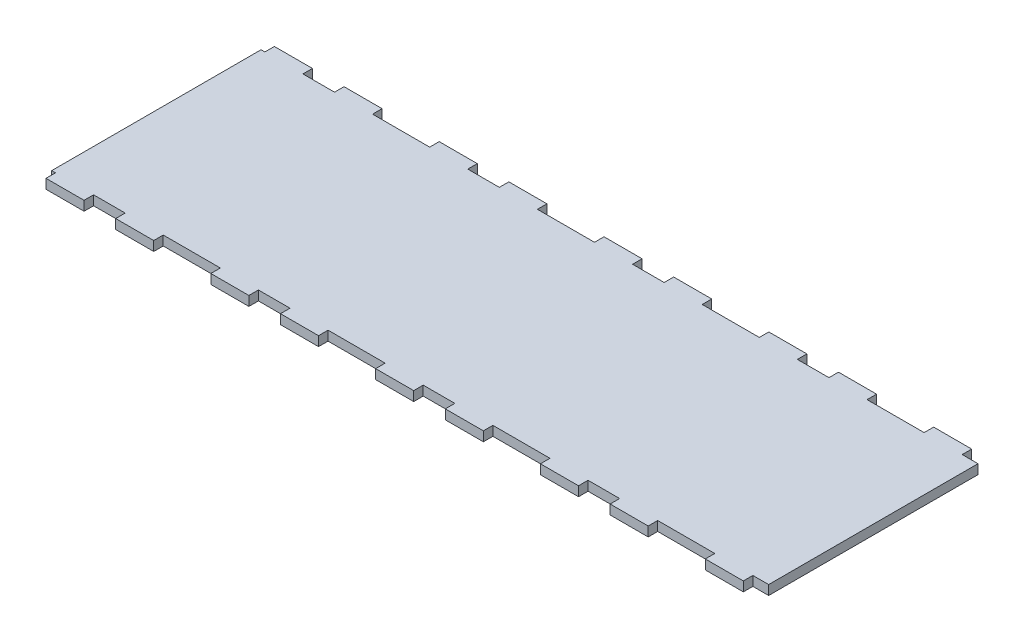
from build123d import *

# Parameters (mm, degrees)
SKETCH1_W                 = 516.930563546
SKETCH1_H                 = 152.4
BOSS_EXTRUDE1_DEPTH       = 6.35
SKETCH2_W                 = 21.085226308
SKETCH2_H                 = 6.35
SKETCH2_W_2               = 19.05
CUT_EXTRUDE1_DEPTH        = 7.35
LPATTERN1_COUNT           = 3
LPATTERN1_PITCH           = 109.985226308
LPATTERN1_COL_COUNT       = 3
LPATTERN1_COL_PITCH       = 109.985226308
MIRROR1_COPY_1_SKETCH_W   = 21.085226308
MIRROR1_COPY_1_SKETCH_H   = 6.35
MIRROR1_COPY_1_SKETCH_W_2 = 19.05
MIRROR1_COPY_1_DEPTH      = 7.35
MIRROR1_COPY_2_SKETCH_W   = 21.085226308
MIRROR1_COPY_2_SKETCH_H   = 6.35
MIRROR1_COPY_2_SKETCH_W_2 = 19.05
MIRROR1_COPY_2_DEPTH      = 7.35
MIRROR1_COPY_3_SKETCH_W   = 21.085226308
MIRROR1_COPY_3_SKETCH_H   = 6.35
MIRROR1_COPY_3_SKETCH_W_2 = 19.05
MIRROR1_COPY_3_DEPTH      = 7.35
MIRROR1_COPY_4_SKETCH_W   = 21.085226308
MIRROR1_COPY_4_SKETCH_H   = 6.35
MIRROR1_COPY_4_SKETCH_W_2 = 19.05
MIRROR1_COPY_4_DEPTH      = 7.35
CUT_EXTRUDE2_DEPTH        = 7.35


with BuildPart() as part:
    # Sketch1 → Boss-Extrude1 (new body)
    with BuildSketch(Plane(origin=(0, 0, 0), x_dir=(1, 0, 0), z_dir=(0, 1, 0))):
        Rectangle(SKETCH1_W, SKETCH1_H)
    extrude(amount=BOSS_EXTRUDE1_DEPTH)

    # Sketch2 → Cut-Extrude1 (cut, through all)
    with BuildSketch(Plane(origin=(0, 6.35, 0), x_dir=(1, 0, 0), z_dir=(0, 1, 0))):
        with Locations((0, -73.025)):
            Rectangle(SKETCH2_W, SKETCH2_H)
        with Locations((-45.467613154, -73.025)):
            Rectangle(SKETCH2_W_2, SKETCH2_H)
        with Locations((45.467613154, -73.025)):
            Rectangle(SKETCH2_W_2, SKETCH2_H)
    cut_extrude1 = extrude(amount=-CUT_EXTRUDE1_DEPTH, mode=Mode.SUBTRACT)

    # LPattern1: Cut-Extrude1 ×3
    with Locations(*[(i * LPATTERN1_PITCH, 0, 0) for i in range(1, LPATTERN1_COUNT)]):
        add(cut_extrude1, mode=Mode.SUBTRACT)

    # LPattern1 col: Cut-Extrude1 ×3
    with Locations(*[(-i * LPATTERN1_COL_PITCH, 0, 0) for i in range(1, LPATTERN1_COL_COUNT)]):
        add(cut_extrude1, mode=Mode.SUBTRACT)

    # Mirror1: Cut-Extrude1 across plane
    add(cut_extrude1.mirror(Plane.XY), mode=Mode.SUBTRACT)

    # Mirror1 copy 1 sketch → Mirror1 copy 1 (cut, through all)
    with BuildSketch(Plane(origin=(109.985226308, 6.35, 0), x_dir=(1, 0, 0), z_dir=(0, 1, 0))):
        with Locations((0, 73.025)):
            Rectangle(MIRROR1_COPY_1_SKETCH_W, MIRROR1_COPY_1_SKETCH_H)
        with Locations((-45.467613154, 73.025)):
            Rectangle(MIRROR1_COPY_1_SKETCH_W_2, MIRROR1_COPY_1_SKETCH_H)
        with Locations((45.467613154, 73.025)):
            Rectangle(MIRROR1_COPY_1_SKETCH_W_2, MIRROR1_COPY_1_SKETCH_H)
    extrude(amount=-MIRROR1_COPY_1_DEPTH, mode=Mode.SUBTRACT)

    # Mirror1 copy 2 sketch → Mirror1 copy 2 (cut, through all)
    with BuildSketch(Plane(origin=(219.970452616, 6.35, 0), x_dir=(1, 0, 0), z_dir=(0, 1, 0))):
        with Locations((0, 73.025)):
            Rectangle(MIRROR1_COPY_2_SKETCH_W, MIRROR1_COPY_2_SKETCH_H)
        with Locations((-45.467613154, 73.025)):
            Rectangle(MIRROR1_COPY_2_SKETCH_W_2, MIRROR1_COPY_2_SKETCH_H)
        with Locations((45.467613154, 73.025)):
            Rectangle(MIRROR1_COPY_2_SKETCH_W_2, MIRROR1_COPY_2_SKETCH_H)
    extrude(amount=-MIRROR1_COPY_2_DEPTH, mode=Mode.SUBTRACT)

    # Mirror1 copy 3 sketch → Mirror1 copy 3 (cut, through all)
    with BuildSketch(Plane(origin=(-109.985226308, 6.35, 0), x_dir=(1, 0, 0), z_dir=(0, 1, 0))):
        with Locations((0, 73.025)):
            Rectangle(MIRROR1_COPY_3_SKETCH_W, MIRROR1_COPY_3_SKETCH_H)
        with Locations((-45.467613154, 73.025)):
            Rectangle(MIRROR1_COPY_3_SKETCH_W_2, MIRROR1_COPY_3_SKETCH_H)
        with Locations((45.467613154, 73.025)):
            Rectangle(MIRROR1_COPY_3_SKETCH_W_2, MIRROR1_COPY_3_SKETCH_H)
    extrude(amount=-MIRROR1_COPY_3_DEPTH, mode=Mode.SUBTRACT)

    # Mirror1 copy 4 sketch → Mirror1 copy 4 (cut, through all)
    with BuildSketch(Plane(origin=(-219.970452616, 6.35, 0), x_dir=(1, 0, 0), z_dir=(0, 1, 0))):
        with Locations((0, 73.025)):
            Rectangle(MIRROR1_COPY_4_SKETCH_W, MIRROR1_COPY_4_SKETCH_H)
        with Locations((-45.467613154, 73.025)):
            Rectangle(MIRROR1_COPY_4_SKETCH_W_2, MIRROR1_COPY_4_SKETCH_H)
        with Locations((45.467613154, 73.025)):
            Rectangle(MIRROR1_COPY_4_SKETCH_W_2, MIRROR1_COPY_4_SKETCH_H)
    extrude(amount=-MIRROR1_COPY_4_DEPTH, mode=Mode.SUBTRACT)

    # Sketch3 → Cut-Extrude2 (cut, through all)
    with BuildSketch(Plane(origin=(0, 6.35, 0), x_dir=(1, 0, 0), z_dir=(0, 1, 0))):
        Polygon((219.970452616, 69.85), (219.970452616, -76.2), (258.465281773, -76.2), (258.465281773, 76.2), (219.970452616, 76.2), align=None)
    extrude(amount=-CUT_EXTRUDE2_DEPTH, mode=Mode.SUBTRACT)


solid = part.part
